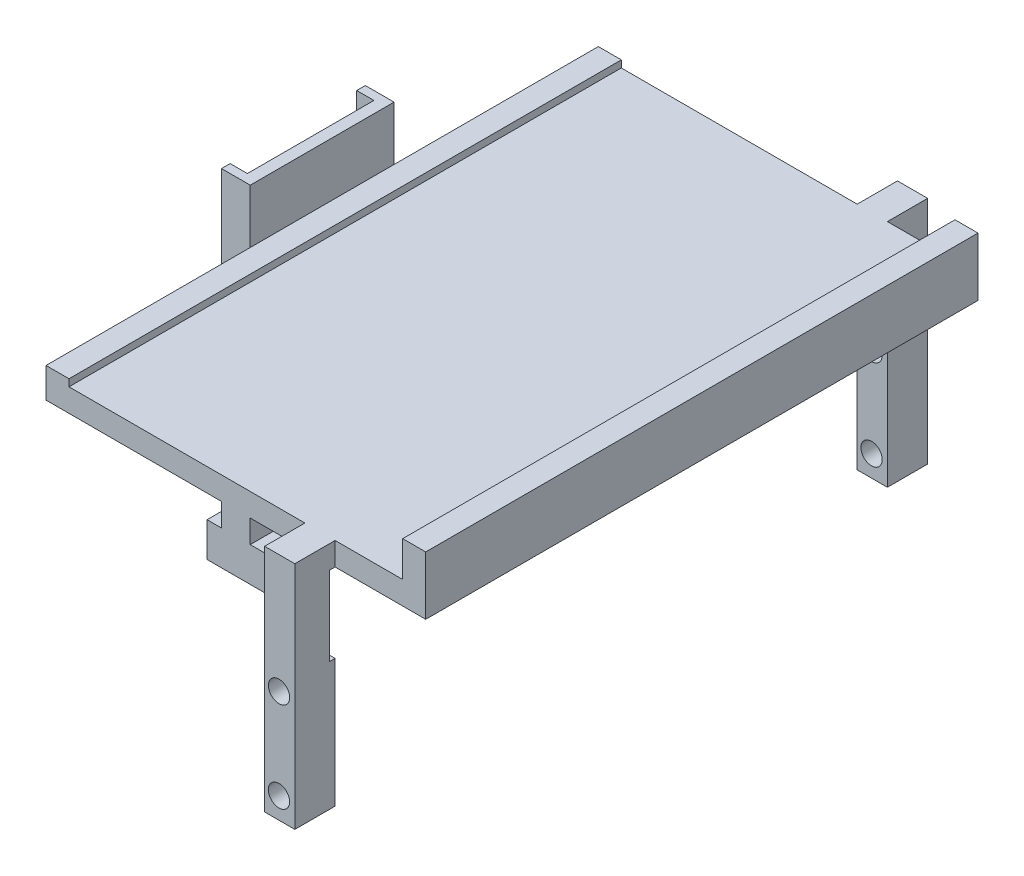
from build123d import *

# Parameters (mm, degrees)
BOSS_EXTRUDE1_DEPTH      = 96
SKETCH3_W                = 68
SKETCH3_H                = 10
CUT_EXTRUDE1_DEPTH       = 96
SKETCH6_W                = 5.25
SKETCH6_H                = 36
BOSS_EXTRUDE3_DEPTH      = 7
BOSS_EXTRUDE3_DEPTH_BACK = 103
SKETCH8_W                = 5.25
SKETCH8_H                = 7
BOSS_EXTRUDE4_DEPTH      = 4
SKETCH10_W               = 5.25
SKETCH10_H               = 7
BOSS_EXTRUDE5_DEPTH      = 4
SKETCH11_W               = 96
SKETCH11_H               = 36
CUT_EXTRUDE2_DEPTH       = 101
SKETCH12_R               = 1.85
CUT_EXTRUDE3_DEPTH       = 111
SKETCH13_W               = 96
SKETCH13_H               = 3.5
CUT_EXTRUDE4_DEPTH       = 10
SKETCH14_W               = 1
SKETCH14_H               = 13.753189639
CUT_EXTRUDE5_DEPTH       = 10
SKETCH15_W               = 25
SKETCH15_H               = 24
BOSS_EXTRUDE6_DEPTH      = 5
SKETCH16_W               = 22
SKETCH16_H               = 24
CUT_EXTRUDE6_DEPTH       = 3


with BuildPart() as part:
    # Sketch1 → Boss-Extrude1 (new body)
    with BuildSketch(Plane.XY):
        Polygon((2.5, 3), (5, 3), (5, -3), (-5, -3), (-5, 3), (-2.5, 3), (-2.5, 7), (-33, 7), (-33, 15.720359308), (-29, 15.720359308), (-29, 11), (29, 11), (29, 17.148290328), (33, 17.148290328), (33, 7), (2.5, 7), align=None)
    extrude(amount=-BOSS_EXTRUDE1_DEPTH)

    # Sketch3 → Cut-Extrude1 (cut)
    with BuildSketch(Plane.ZY.offset(5)):
        with Locations((-48, 2)):
            Rectangle(SKETCH3_W, SKETCH3_H)
    extrude(amount=-CUT_EXTRUDE1_DEPTH, mode=Mode.SUBTRACT)

    # Sketch6 → Boss-Extrude3 (add, two sides)
    with BuildSketch(Plane.XY) as boss_extrude3_sk:
        with Locations((14.625, -11)):
            Rectangle(SKETCH6_W, SKETCH6_H)
    extrude(amount=BOSS_EXTRUDE3_DEPTH)
    extrude(boss_extrude3_sk.sketch, amount=-BOSS_EXTRUDE3_DEPTH_BACK)

    # Sketch8 → Boss-Extrude4 (add)
    with BuildSketch(Plane(origin=(0, 7, 0), x_dir=(1, 0, 0), z_dir=(0, 1, 0))):
        with Locations((14.625, 99.5)):
            Rectangle(SKETCH8_W, SKETCH8_H)
    extrude(amount=BOSS_EXTRUDE4_DEPTH)

    # Sketch10 → Boss-Extrude5 (add)
    with BuildSketch(Plane(origin=(0, 7, 0), x_dir=(1, 0, 0), z_dir=(0, 1, 0))):
        with Locations((14.625, -3.5)):
            Rectangle(SKETCH10_W, SKETCH10_H)
    extrude(amount=BOSS_EXTRUDE5_DEPTH)

    # Sketch11 → Cut-Extrude2 (cut)
    with BuildSketch(Plane.ZY.offset(-12)):
        with Locations((-48, -11)):
            Rectangle(SKETCH11_W, SKETCH11_H)
    extrude(amount=-CUT_EXTRUDE2_DEPTH, mode=Mode.SUBTRACT)

    # Sketch12 → Cut-Extrude3 (cut, through all)
    with BuildSketch(Plane.XY.offset(7)):
        with Locations((14.5, -25.3)):
            Circle(SKETCH12_R)
        with Locations((14.5, -9.6)):
            Circle(SKETCH12_R)
    extrude(amount=-CUT_EXTRUDE3_DEPTH, mode=Mode.SUBTRACT)

    # Sketch13 → Cut-Extrude4 (cut)
    with BuildSketch(Plane.ZY.offset(33)):
        with Locations((-48, 13.970359308)):
            Rectangle(SKETCH13_W, SKETCH13_H)
    extrude(amount=-CUT_EXTRUDE4_DEPTH, mode=Mode.SUBTRACT)

    # Sketch14 → Cut-Extrude5 (cut)
    with BuildSketch(Plane.ZY.offset(-12)):
        with Locations((0.5, 0.12340518)):
            Rectangle(SKETCH14_W, SKETCH14_H)
        with Locations((-96.5, 0.12340518)):
            Rectangle(SKETCH14_W, SKETCH14_H)
    extrude(amount=-CUT_EXTRUDE5_DEPTH, mode=Mode.SUBTRACT)

    # Sketch15 → Boss-Extrude6 (add)
    with BuildSketch(Plane.ZY.offset(33)):
        with Locations((-48, 9.610179654)):
            Rectangle(SKETCH15_W, SKETCH15_H)
    extrude(amount=BOSS_EXTRUDE6_DEPTH)

    # Sketch16 → Cut-Extrude6 (cut)
    with BuildSketch(Plane.ZY.offset(38)):
        with Locations((-48, 9.610179654)):
            Rectangle(SKETCH16_W, SKETCH16_H)
    extrude(amount=-CUT_EXTRUDE6_DEPTH, mode=Mode.SUBTRACT)


solid = part.part
